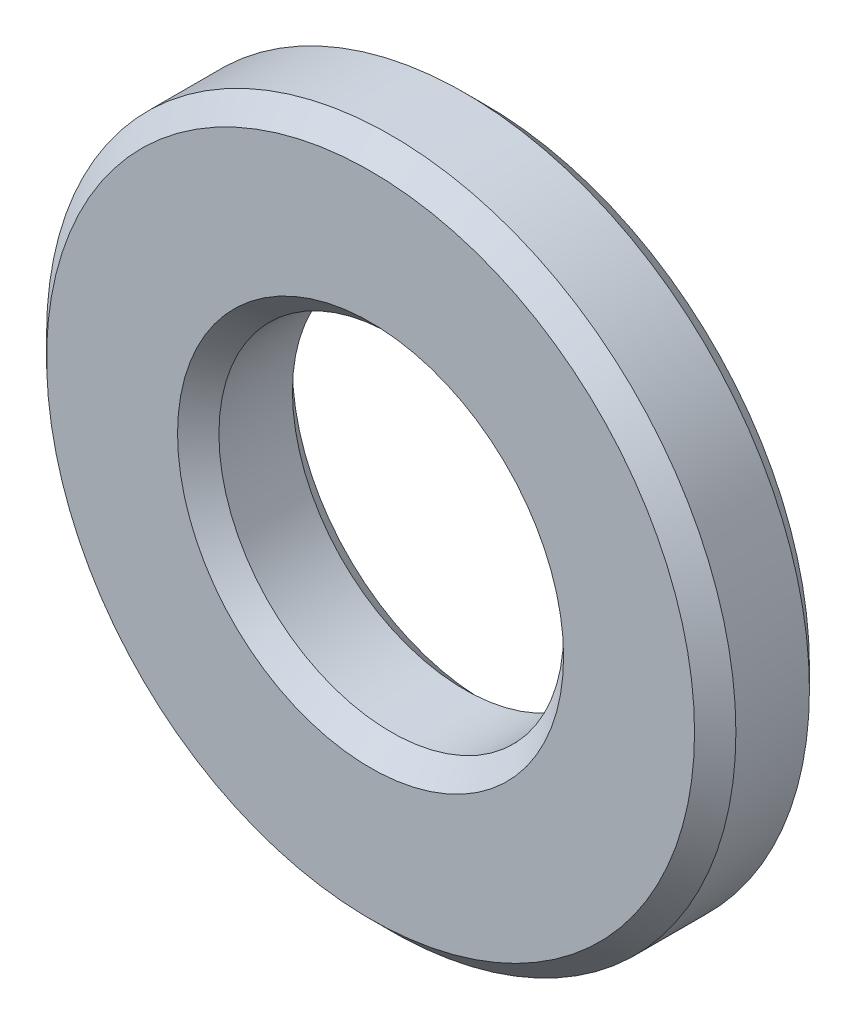
from build123d import *

# Parameters (mm, degrees)
SKETCH3_R                = 19.05
SKETCH3_R_2              = 9.525
BOSS_EXTRUDE1_DEPTH      = 3.175
BOSS_EXTRUDE1_DEPTH_BACK = 3.175
CHAMFER1_SIZE            = 1.143


with BuildPart() as part:
    # Sketch3 → Boss-Extrude1 (new body, two sides)
    with BuildSketch(Plane.XY) as boss_extrude1_sk:
        Circle(SKETCH3_R)
        Circle(SKETCH3_R_2, mode=Mode.SUBTRACT)
    extrude(amount=BOSS_EXTRUDE1_DEPTH)
    extrude(boss_extrude1_sk.sketch, amount=-BOSS_EXTRUDE1_DEPTH_BACK)

    # Chamfer1
    chamfer1_edges = [part.edges().sort_by_distance(p)[0] for p in [
        (-19.05, 0, -3.175),
        (-9.525, 0, -3.175),
        (-19.05, 0, 3.175),
        (-9.525, 0, 3.175),
    ]]
    chamfer(chamfer1_edges, length=CHAMFER1_SIZE)


solid = part.part
